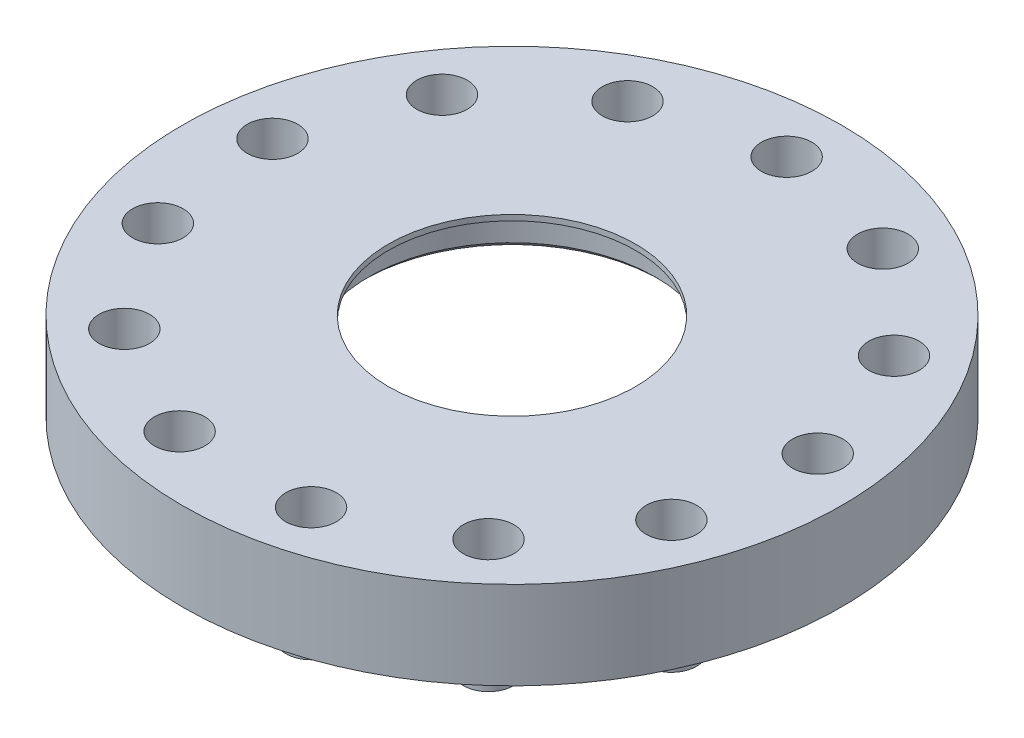
from build123d import *

# Parameters (mm, degrees)
SKETCH1_R           = 60
SKETCH1_R_2         = 26.1
SKETCH1_R_3         = 2.6
BOSS_EXTRUDE1_DEPTH = 8
SKETCH2_R           = 60
SKETCH2_R_2         = 40
SKETCH2_R_3         = 2.6
BOSS_EXTRUDE2_DEPTH = 8
SKETCH3_R           = 4.6
SKETCH3_R_2         = 2.6
BOSS_EXTRUDE3_DEPTH = 4.8
SKETCH4_R           = 26.1
SKETCH4_R_2         = 22.5
BOSS_EXTRUDE4_DEPTH = 1
CHAMFER1_SIZE       = 1
SKETCH5_R           = 4.6
SKETCH5_R_2         = 2.6
CUT_EXTRUDE1_DEPTH  = 7


with BuildPart() as part:
    # Sketch1 → Boss-Extrude1 (new body)
    with BuildSketch(Plane(origin=(0, 0, 0), x_dir=(1, 0, 0), z_dir=(0, 1, 0))):
        Circle(SKETCH1_R)
        Circle(SKETCH1_R_2, mode=Mode.SUBTRACT)
        with Locations((0, 50)):
            Circle(SKETCH1_R_3, mode=Mode.SUBTRACT)
        with Locations((23.236158602, 44.272801283)):
            Circle(SKETCH1_R_3, mode=Mode.SUBTRACT)
        with Locations((41.149193295, 28.403237337)):
            Circle(SKETCH1_R_3, mode=Mode.SUBTRACT)
        with Locations((49.635443705, 6.026834013)):
            Circle(SKETCH1_R_3, mode=Mode.SUBTRACT)
        with Locations((46.750812134, -17.730244352)):
            Circle(SKETCH1_R_3, mode=Mode.SUBTRACT)
        with Locations((33.156132912, -37.425537409)):
            Circle(SKETCH1_R_3, mode=Mode.SUBTRACT)
        with Locations((11.965783214, -48.547090871)):
            Circle(SKETCH1_R_3, mode=Mode.SUBTRACT)
        with Locations((-11.965783214, -48.547090871)):
            Circle(SKETCH1_R_3, mode=Mode.SUBTRACT)
        with Locations((-33.156132912, -37.425537409)):
            Circle(SKETCH1_R_3, mode=Mode.SUBTRACT)
        with Locations((-46.750812134, -17.730244352)):
            Circle(SKETCH1_R_3, mode=Mode.SUBTRACT)
        with Locations((-49.635443705, 6.026834013)):
            Circle(SKETCH1_R_3, mode=Mode.SUBTRACT)
        with Locations((-41.149193295, 28.403237337)):
            Circle(SKETCH1_R_3, mode=Mode.SUBTRACT)
        with Locations((-23.236158602, 44.272801283)):
            Circle(SKETCH1_R_3, mode=Mode.SUBTRACT)
    extrude(amount=BOSS_EXTRUDE1_DEPTH)

    # Sketch2 → Boss-Extrude2 (add)
    with BuildSketch(Plane(origin=(0, 0, 0), x_dir=(-1, 0, 0), z_dir=(0, -1, 0))):
        Circle(SKETCH2_R)
        Circle(SKETCH2_R_2, mode=Mode.SUBTRACT)
        with Locations((23.236158602, 44.272801283)):
            Circle(SKETCH2_R_3, mode=Mode.SUBTRACT)
        with Locations((41.149193295, 28.403237337)):
            Circle(SKETCH2_R_3, mode=Mode.SUBTRACT)
        with Locations((49.635443705, 6.026834013)):
            Circle(SKETCH2_R_3, mode=Mode.SUBTRACT)
        with Locations((46.750812134, -17.730244352)):
            Circle(SKETCH2_R_3, mode=Mode.SUBTRACT)
        with Locations((33.156132912, -37.425537409)):
            Circle(SKETCH2_R_3, mode=Mode.SUBTRACT)
        with Locations((11.965783214, -48.547090871)):
            Circle(SKETCH2_R_3, mode=Mode.SUBTRACT)
        with Locations((-11.965783214, -48.547090871)):
            Circle(SKETCH2_R_3, mode=Mode.SUBTRACT)
        with Locations((-33.156132912, -37.425537409)):
            Circle(SKETCH2_R_3, mode=Mode.SUBTRACT)
        with Locations((-46.750812134, -17.730244352)):
            Circle(SKETCH2_R_3, mode=Mode.SUBTRACT)
        with Locations((-49.635443705, 6.026834013)):
            Circle(SKETCH2_R_3, mode=Mode.SUBTRACT)
        with Locations((-41.149193295, 28.403237337)):
            Circle(SKETCH2_R_3, mode=Mode.SUBTRACT)
        with Locations((-23.236158602, 44.272801283)):
            Circle(SKETCH2_R_3, mode=Mode.SUBTRACT)
        with Locations((0, 50)):
            Circle(SKETCH2_R_3, mode=Mode.SUBTRACT)
    extrude(amount=BOSS_EXTRUDE2_DEPTH)

    # Sketch3 → Boss-Extrude3 (add)
    with BuildSketch(Plane.XZ.offset(8)):
        with Locations((0, -50)):
            Circle(SKETCH3_R)
        with Locations((0, -50)):
            Circle(SKETCH3_R_2, mode=Mode.SUBTRACT)
        with Locations((41.149193295, -28.403237337)):
            Circle(SKETCH3_R)
        with Locations((41.149193295, -28.403237337)):
            Circle(SKETCH3_R_2, mode=Mode.SUBTRACT)
        with Locations((46.750812134, 17.730244352)):
            Circle(SKETCH3_R)
        with Locations((46.750812134, 17.730244352)):
            Circle(SKETCH3_R_2, mode=Mode.SUBTRACT)
        with Locations((11.965783214, 48.547090871)):
            Circle(SKETCH3_R)
        with Locations((11.965783214, 48.547090871)):
            Circle(SKETCH3_R_2, mode=Mode.SUBTRACT)
        with Locations((-33.156132912, 37.425537409)):
            Circle(SKETCH3_R)
        with Locations((-33.156132912, 37.425537409)):
            Circle(SKETCH3_R_2, mode=Mode.SUBTRACT)
        with Locations((-49.635443705, -6.026834013)):
            Circle(SKETCH3_R)
        with Locations((-49.635443705, -6.026834013)):
            Circle(SKETCH3_R_2, mode=Mode.SUBTRACT)
        with Locations((-23.236158602, -44.272801283)):
            Circle(SKETCH3_R)
        with Locations((-23.236158602, -44.272801283)):
            Circle(SKETCH3_R_2, mode=Mode.SUBTRACT)
        with Locations((-41.149193295, -28.403237337)):
            Circle(SKETCH3_R)
        with Locations((-41.149193295, -28.403237337)):
            Circle(SKETCH3_R_2, mode=Mode.SUBTRACT)
        with Locations((-46.750812134, 17.730244352)):
            Circle(SKETCH3_R)
        with Locations((-46.750812134, 17.730244352)):
            Circle(SKETCH3_R_2, mode=Mode.SUBTRACT)
        with Locations((-11.965783214, 48.547090871)):
            Circle(SKETCH3_R)
        with Locations((-11.965783214, 48.547090871)):
            Circle(SKETCH3_R_2, mode=Mode.SUBTRACT)
        with Locations((33.156132912, 37.425537409)):
            Circle(SKETCH3_R)
        with Locations((33.156132912, 37.425537409)):
            Circle(SKETCH3_R_2, mode=Mode.SUBTRACT)
        with Locations((49.635443705, -6.026834013)):
            Circle(SKETCH3_R)
        with Locations((49.635443705, -6.026834013)):
            Circle(SKETCH3_R_2, mode=Mode.SUBTRACT)
        with Locations((23.236158602, -44.272801283)):
            Circle(SKETCH3_R)
        with Locations((23.236158602, -44.272801283)):
            Circle(SKETCH3_R_2, mode=Mode.SUBTRACT)
    extrude(amount=BOSS_EXTRUDE3_DEPTH)

    # Sketch4 → Boss-Extrude4 (add)
    with BuildSketch(Plane(origin=(0, 8, 0), x_dir=(1, 0, 0), z_dir=(0, 1, 0))):
        Circle(SKETCH4_R)
        Circle(SKETCH4_R_2, mode=Mode.SUBTRACT)
    extrude(amount=-BOSS_EXTRUDE4_DEPTH)

    # Chamfer1
    chamfer1_edges = [part.edges().sort_by_distance(p)[0] for p in [
        (-26.1, 0, 0),
    ]]
    chamfer(chamfer1_edges, length=CHAMFER1_SIZE)

    # Sketch5 → Cut-Extrude1 (cut)
    with BuildSketch(Plane(origin=(0, 8, 0), x_dir=(1, 0, 0), z_dir=(0, 1, 0))):
        with Locations((-23.236158602, 44.272801283)):
            Circle(SKETCH5_R)
        with Locations((-23.236158602, 44.272801283)):
            Circle(SKETCH5_R_2, mode=Mode.SUBTRACT)
        with Locations((-49.635443705, 6.026834013)):
            Circle(SKETCH5_R)
        with Locations((-49.635443705, 6.026834013)):
            Circle(SKETCH5_R_2, mode=Mode.SUBTRACT)
        with Locations((-33.156132912, -37.425537409)):
            Circle(SKETCH5_R)
        with Locations((-33.156132912, -37.425537409)):
            Circle(SKETCH5_R_2, mode=Mode.SUBTRACT)
        with Locations((11.965783214, -48.547090871)):
            Circle(SKETCH5_R)
        with Locations((11.965783214, -48.547090871)):
            Circle(SKETCH5_R_2, mode=Mode.SUBTRACT)
        with Locations((46.750812134, -17.730244352)):
            Circle(SKETCH5_R)
        with Locations((46.750812134, -17.730244352)):
            Circle(SKETCH5_R_2, mode=Mode.SUBTRACT)
        with Locations((41.149193295, 28.403237337)):
            Circle(SKETCH5_R)
        with Locations((41.149193295, 28.403237337)):
            Circle(SKETCH5_R_2, mode=Mode.SUBTRACT)
        with Locations((0, 50)):
            Circle(SKETCH5_R)
        with Locations((0, 50)):
            Circle(SKETCH5_R_2, mode=Mode.SUBTRACT)
        with Locations((23.236158602, 44.272801283)):
            Circle(SKETCH5_R)
        with Locations((23.236158602, 44.272801283)):
            Circle(SKETCH5_R_2, mode=Mode.SUBTRACT)
        with Locations((49.635443705, 6.026834013)):
            Circle(SKETCH5_R)
        with Locations((49.635443705, 6.026834013)):
            Circle(SKETCH5_R_2, mode=Mode.SUBTRACT)
        with Locations((33.156132912, -37.425537409)):
            Circle(SKETCH5_R)
        with Locations((33.156132912, -37.425537409)):
            Circle(SKETCH5_R_2, mode=Mode.SUBTRACT)
        with Locations((-11.965783214, -48.547090871)):
            Circle(SKETCH5_R)
        with Locations((-11.965783214, -48.547090871)):
            Circle(SKETCH5_R_2, mode=Mode.SUBTRACT)
        with Locations((-46.750812134, -17.730244352)):
            Circle(SKETCH5_R)
        with Locations((-46.750812134, -17.730244352)):
            Circle(SKETCH5_R_2, mode=Mode.SUBTRACT)
        with Locations((-41.149193295, 28.403237337)):
            Circle(SKETCH5_R)
        with Locations((-41.149193295, 28.403237337)):
            Circle(SKETCH5_R_2, mode=Mode.SUBTRACT)
    extrude(amount=-CUT_EXTRUDE1_DEPTH, mode=Mode.SUBTRACT)


solid = part.part
